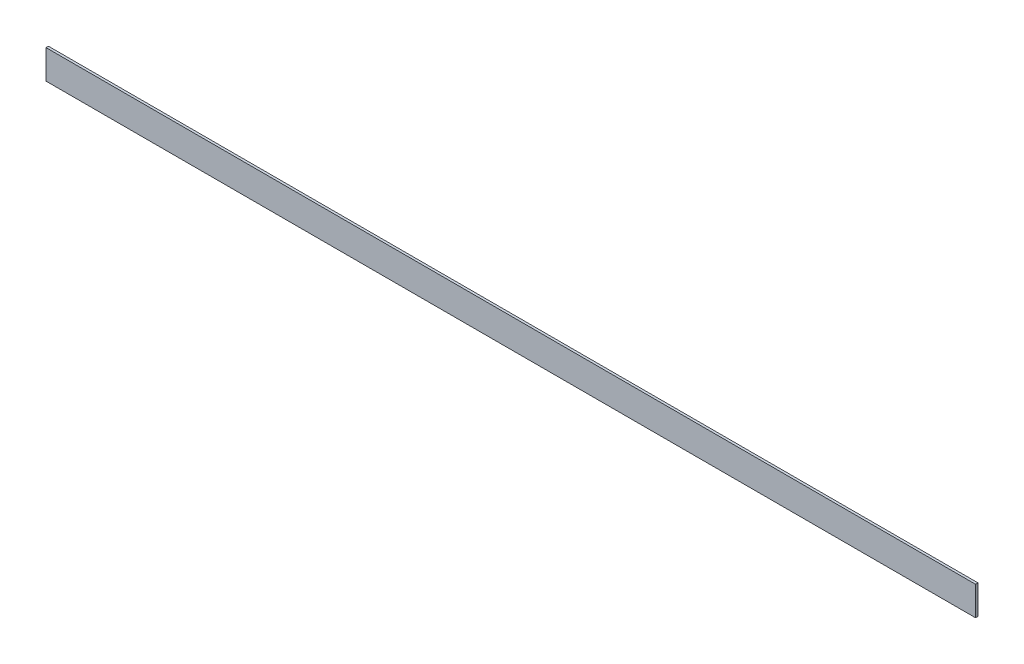
from build123d import *

# Parameters (mm, degrees)
SKETCH1_W           = 6.35
SKETCH1_H           = 76.2
BOSS_EXTRUDE1_DEPTH = 2438.4


with BuildPart() as part:
    # Sketch1 → Boss-Extrude1 (new body)
    with BuildSketch(Plane(origin=(0, 0, 0), x_dir=(0, 0, -1), z_dir=(1, 0, 0))):
        Rectangle(SKETCH1_W, SKETCH1_H)
    extrude(amount=BOSS_EXTRUDE1_DEPTH)


solid = part.part
